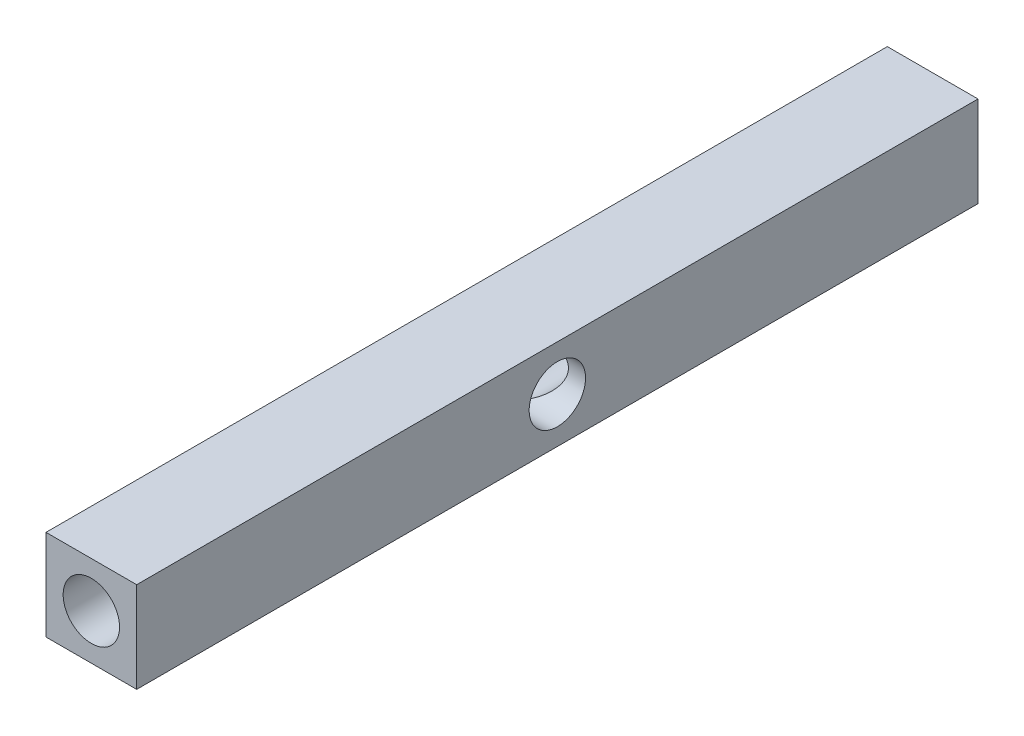
from build123d import *

# Parameters (mm, degrees)
ESBO_O1_W                  = 4.5
ESBO_O1_H                  = 41.75
RESSALTO_EXTRUS_O1_DEPTH   = 2.25
ESBO_O2_R                  = 1.4
CORTE_EXTRUS_O1_DEPTH      = 1
CORTE_EXTRUS_O1_DEPTH_BACK = 42.75
ESBO_O3_R                  = 1.4
CORTE_EXTRUS_O2_DEPTH      = 1
CORTE_EXTRUS_O2_DEPTH_BACK = 5.5


with BuildPart() as part:
    # Esboço1 → Ressalto-extrusão1 (new body, symmetric)
    with BuildSketch(Plane(origin=(0, 0, 0), x_dir=(1, 0, 0), z_dir=(0, 1, 0))):
        Rectangle(ESBO_O1_W, ESBO_O1_H)
    extrude(amount=RESSALTO_EXTRUS_O1_DEPTH, both=True)

    # Esboço2 → Corte-extrusão1 (cut, two sides)
    with BuildSketch(Plane.XY.offset(20.875)) as corte_extrus_o1_sk:
        Circle(ESBO_O2_R)
    extrude(amount=CORTE_EXTRUS_O1_DEPTH, mode=Mode.SUBTRACT)
    extrude(corte_extrus_o1_sk.sketch, amount=-CORTE_EXTRUS_O1_DEPTH_BACK, mode=Mode.SUBTRACT)

    # Esboço3 → Corte-extrusão2 (cut, two sides)
    with BuildSketch(Plane(origin=(-2.25, 0, 0), x_dir=(0, -1, 0), z_dir=(-1, 0, 0))) as corte_extrus_o2_sk:
        Circle(ESBO_O3_R)
    extrude(amount=CORTE_EXTRUS_O2_DEPTH, mode=Mode.SUBTRACT)
    extrude(corte_extrus_o2_sk.sketch, amount=-CORTE_EXTRUS_O2_DEPTH_BACK, mode=Mode.SUBTRACT)


solid = part.part
